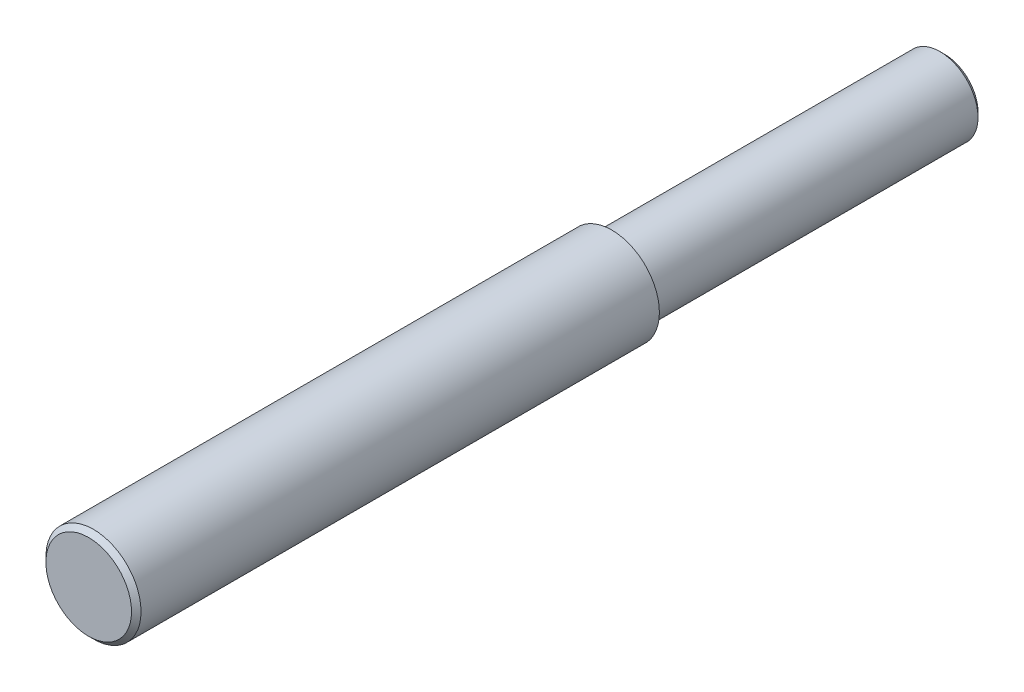
from build123d import *

# Parameters (mm, degrees)
SKETCH1_R           = 1
BOSS_EXTRUDE1_DEPTH = 18
SKETCH2_OUTSIDE_W   = 7.644
SKETCH2_OUTSIDE_H   = 7.644
SKETCH2_OUTSIDE_R   = 0.8
CUT_EXTRUDE1_DEPTH  = 7
CHAMFER1_SIZE       = 0.1
CHAMFER2_SIZE       = 0.1


with BuildPart() as part:
    # Sketch1 → Boss-Extrude1 (new body)
    with BuildSketch(Plane.XY):
        Circle(SKETCH1_R)
    extrude(amount=-BOSS_EXTRUDE1_DEPTH)

    # Sketch2 outside → Cut-Extrude1 (cut)
    with BuildSketch(Plane(origin=(0, 0, -18), x_dir=(-1, 0, 0), z_dir=(0, 0, -1))):
        Rectangle(SKETCH2_OUTSIDE_W, SKETCH2_OUTSIDE_H)
        Circle(SKETCH2_OUTSIDE_R, mode=Mode.SUBTRACT)
    extrude(amount=-CUT_EXTRUDE1_DEPTH, mode=Mode.SUBTRACT)

    # Chamfer1
    chamfer1_edges = [part.edges().sort_by_distance(p)[0] for p in [
        (0.8, 0, -18),
    ]]
    chamfer(chamfer1_edges, length=CHAMFER1_SIZE)

    # Chamfer2
    chamfer2_edges = [part.edges().sort_by_distance(p)[0] for p in [
        (-1, 0, 0),
    ]]
    chamfer(chamfer2_edges, length=CHAMFER2_SIZE)


solid = part.part
